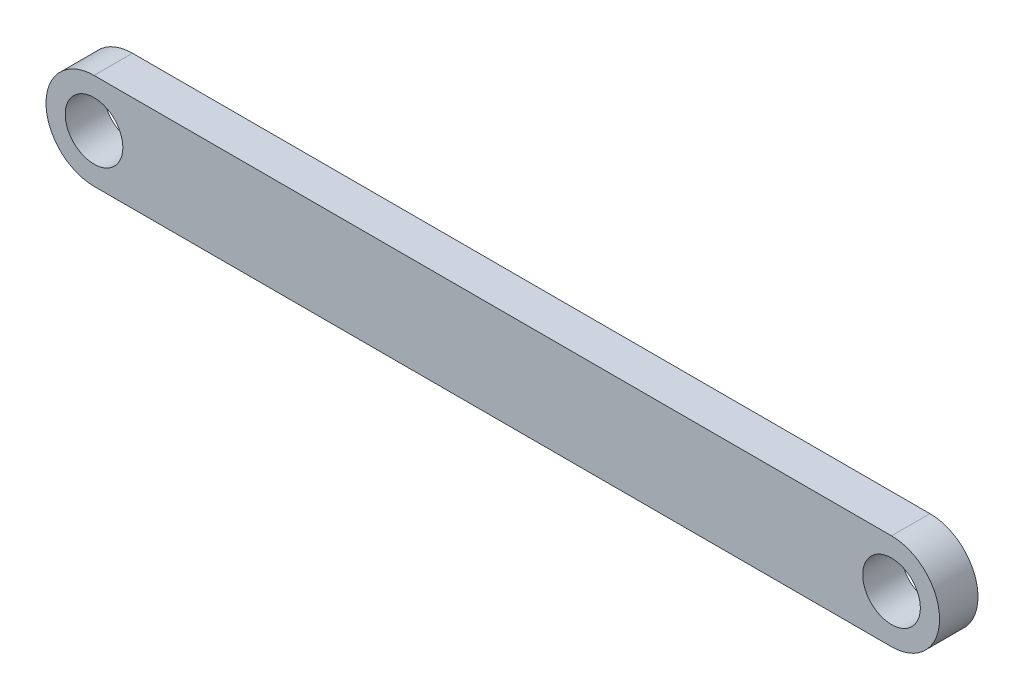
from build123d import *

# Parameters (mm, degrees)
SKETCH1_R           = 1.5
BOSS_EXTRUDE1_DEPTH = 2


with BuildPart() as part:
    # Sketch1 → Boss-Extrude1 (new body)
    with BuildSketch(Plane.XY):
        with BuildLine():
            Line((-0.043904724, 2.483957995), (41.456095276, 2.483957995))
            ThreePointArc((41.456095276, 2.483957995), (43.956095276, -0.016042005), (41.456095276, -2.516042005))
            Line((41.456095276, -2.516042005), (-0.043904724, -2.516042005))
            ThreePointArc((-0.043904724, -2.516042005), (-2.543904724, -0.016042005), (-0.043904724, 2.483957995))
        make_face()
        with Locations((-0.043904724, -0.016042005)):
            Circle(SKETCH1_R, mode=Mode.SUBTRACT)
        with Locations((41.456095276, -0.016042005)):
            Circle(SKETCH1_R, mode=Mode.SUBTRACT)
    extrude(amount=BOSS_EXTRUDE1_DEPTH)


solid = part.part
